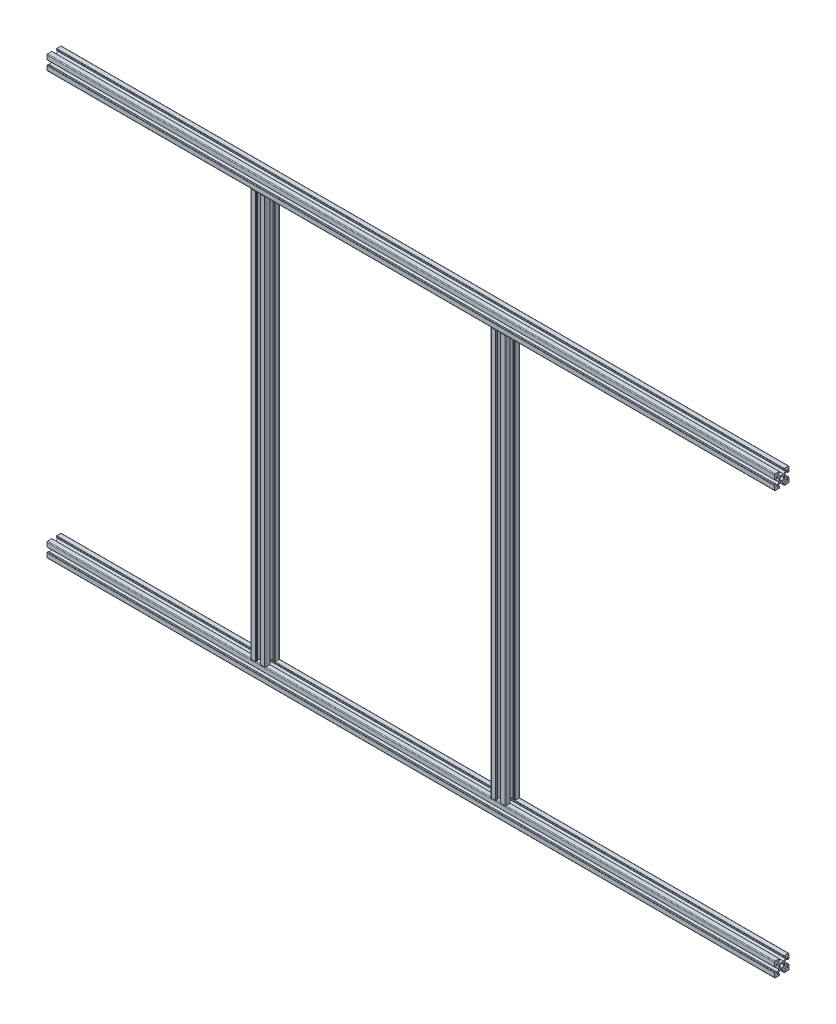
from build123d import *

# Parameters (mm, degrees)
SKETCH1_R                               = 2.5
ALUMINIUM_PROF_ALUMINIUM_PROF_1_DEPTH   = 1000
SKETCH1_ON_SEGMENT_2_R                  = 2.5
ALUMINIUM_PROF_ALUMINIUM_PROF_1_2_DEPTH = 1000
SKETCH11_R                              = 2.5
ALUMINIUM_PROF_ALUMINIUM_PROF_2_DEPTH   = 580
SKETCH11_ON_SEGMENT_2_R                 = 2.5
ALUMINIUM_PROF_ALUMINIUM_PROF_2_2_DEPTH = 580
SKETCH12_R                              = 2.5
CUT_EXTRUDE1_DEPTH                      = 10


with BuildPart() as part:
    # Sketch1 → Aluminium prof ALUMINIUM PROF(1) (new body)
    with BuildSketch(Plane(origin=(-437.898089172, 365.031847134, 0), x_dir=(0, 1, 0), z_dir=(1, 0, 0))):
        with BuildLine():
            Line((-2.5, 4), (2.5, 4))
            Line((2.5, 4), (6.035533906, 7.535533906))
            Line((6.035533906, 7.535533906), (3.535533906, 7.535533906))
            ThreePointArc((3.535533906, 7.535533906), (3.181980515, 7.681980515), (3.035533906, 8.035533906))
            Line((3.035533906, 8.035533906), (3.035533906, 9.535533906))
            ThreePointArc((3.035533906, 9.535533906), (3.181980515, 9.889087297), (3.535533906, 10.035533906))
            Line((3.535533906, 10.035533906), (9.035533906, 10.035533906))
            ThreePointArc((9.035533906, 10.035533906), (9.742640687, 9.742640687), (10.035533906, 9.035533906))
            Line((10.035533906, 9.035533906), (10.035533906, 3.535533906))
            ThreePointArc((10.035533906, 3.535533906), (9.889087297, 3.181980515), (9.535533906, 3.035533906))
            Line((9.535533906, 3.035533906), (8.035533906, 3.035533906))
            ThreePointArc((8.035533906, 3.035533906), (7.681980515, 3.181980515), (7.535533906, 3.535533906))
            Line((7.535533906, 3.535533906), (7.535533906, 6.035533906))
            Line((7.535533906, 6.035533906), (4, 2.5))
            Line((4, 2.5), (4, -2.5))
            Line((4, -2.5), (7.535533906, -6.035533906))
            Line((7.535533906, -6.035533906), (7.535533906, -3.535533906))
            ThreePointArc((7.535533906, -3.535533906), (7.681980515, -3.181980515), (8.035533906, -3.035533906))
            Line((8.035533906, -3.035533906), (9.535533906, -3.035533906))
            ThreePointArc((9.535533906, -3.035533906), (9.889087297, -3.181980515), (10.035533906, -3.535533906))
            Line((10.035533906, -3.535533906), (10.035533906, -9.035533906))
            ThreePointArc((10.035533906, -9.035533906), (9.742640687, -9.742640687), (9.035533906, -10.035533906))
            Line((9.035533906, -10.035533906), (3.535533906, -10.035533906))
            ThreePointArc((3.535533906, -10.035533906), (3.181980515, -9.889087297), (3.035533906, -9.535533906))
            Line((3.035533906, -9.535533906), (3.035533906, -8.035533906))
            ThreePointArc((3.035533906, -8.035533906), (3.181980515, -7.681980515), (3.535533906, -7.535533906))
            Line((3.535533906, -7.535533906), (6.035533906, -7.535533906))
            Line((6.035533906, -7.535533906), (2.5, -4))
            Line((2.5, -4), (-2.5, -4))
            Line((-2.5, -4), (-6.035533906, -7.535533906))
            Line((-6.035533906, -7.535533906), (-3.535533906, -7.535533906))
            ThreePointArc((-3.535533906, -7.535533906), (-3.181980515, -7.681980515), (-3.035533906, -8.035533906))
            Line((-3.035533906, -8.035533906), (-3.035533906, -9.535533906))
            ThreePointArc((-3.035533906, -9.535533906), (-3.181980515, -9.889087297), (-3.535533906, -10.035533906))
            Line((-3.535533906, -10.035533906), (-9.035533906, -10.035533906))
            ThreePointArc((-9.035533906, -10.035533906), (-9.742640687, -9.742640687), (-10.035533906, -9.035533906))
            Line((-10.035533906, -9.035533906), (-10.035533906, -3.535533906))
            ThreePointArc((-10.035533906, -3.535533906), (-9.889087297, -3.181980515), (-9.535533906, -3.035533906))
            Line((-9.535533906, -3.035533906), (-8.035533906, -3.035533906))
            ThreePointArc((-8.035533906, -3.035533906), (-7.681980515, -3.181980515), (-7.535533906, -3.535533906))
            Line((-7.535533906, -3.535533906), (-7.535533906, -6.035533906))
            Line((-7.535533906, -6.035533906), (-4, -2.5))
            Line((-4, -2.5), (-4, 2.5))
            Line((-4, 2.5), (-7.535533906, 6.035533906))
            Line((-7.535533906, 6.035533906), (-7.535533906, 3.535533906))
            ThreePointArc((-7.535533906, 3.535533906), (-7.681980515, 3.181980515), (-8.035533906, 3.035533906))
            Line((-8.035533906, 3.035533906), (-9.535533906, 3.035533906))
            ThreePointArc((-9.535533906, 3.035533906), (-9.889087297, 3.181980515), (-10.035533906, 3.535533906))
            Line((-10.035533906, 3.535533906), (-10.035533906, 9.035533906))
            ThreePointArc((-10.035533906, 9.035533906), (-9.742640687, 9.742640687), (-9.035533906, 10.035533906))
            Line((-9.035533906, 10.035533906), (-3.535533906, 10.035533906))
            ThreePointArc((-3.535533906, 10.035533906), (-3.181980515, 9.889087297), (-3.035533906, 9.535533906))
            Line((-3.035533906, 9.535533906), (-3.035533906, 8.035533906))
            ThreePointArc((-3.035533906, 8.035533906), (-3.181980515, 7.681980515), (-3.535533906, 7.535533906))
            Line((-3.535533906, 7.535533906), (-6.035533906, 7.535533906))
            Line((-6.035533906, 7.535533906), (-2.5, 4))
        make_face()
        Circle(SKETCH1_R, mode=Mode.SUBTRACT)
    extrude(amount=ALUMINIUM_PROF_ALUMINIUM_PROF_1_DEPTH)


with BuildPart() as body_2:
    # Sketch1 on segment 2 (carried to segment 2) → Aluminium prof ALUMINIUM PROF_1 2 (new body)
    with BuildSketch(Plane(origin=(-437.898089172, -214.968152866, 0), x_dir=(0, 1, 0), z_dir=(1, 0, 0))):
        with BuildLine():
            Line((-2.5, 4), (2.5, 4))
            Line((2.5, 4), (6.035533906, 7.535533906))
            Line((6.035533906, 7.535533906), (3.535533906, 7.535533906))
            ThreePointArc((3.535533906, 7.535533906), (3.181980515, 7.681980515), (3.035533906, 8.035533906))
            Line((3.035533906, 8.035533906), (3.035533906, 9.535533906))
            ThreePointArc((3.035533906, 9.535533906), (3.181980515, 9.889087297), (3.535533906, 10.035533906))
            Line((3.535533906, 10.035533906), (9.035533906, 10.035533906))
            ThreePointArc((9.035533906, 10.035533906), (9.742640687, 9.742640687), (10.035533906, 9.035533906))
            Line((10.035533906, 9.035533906), (10.035533906, 3.535533906))
            ThreePointArc((10.035533906, 3.535533906), (9.889087297, 3.181980515), (9.535533906, 3.035533906))
            Line((9.535533906, 3.035533906), (8.035533906, 3.035533906))
            ThreePointArc((8.035533906, 3.035533906), (7.681980515, 3.181980515), (7.535533906, 3.535533906))
            Line((7.535533906, 3.535533906), (7.535533906, 6.035533906))
            Line((7.535533906, 6.035533906), (4, 2.5))
            Line((4, 2.5), (4, -2.5))
            Line((4, -2.5), (7.535533906, -6.035533906))
            Line((7.535533906, -6.035533906), (7.535533906, -3.535533906))
            ThreePointArc((7.535533906, -3.535533906), (7.681980515, -3.181980515), (8.035533906, -3.035533906))
            Line((8.035533906, -3.035533906), (9.535533906, -3.035533906))
            ThreePointArc((9.535533906, -3.035533906), (9.889087297, -3.181980515), (10.035533906, -3.535533906))
            Line((10.035533906, -3.535533906), (10.035533906, -9.035533906))
            ThreePointArc((10.035533906, -9.035533906), (9.742640687, -9.742640687), (9.035533906, -10.035533906))
            Line((9.035533906, -10.035533906), (3.535533906, -10.035533906))
            ThreePointArc((3.535533906, -10.035533906), (3.181980515, -9.889087297), (3.035533906, -9.535533906))
            Line((3.035533906, -9.535533906), (3.035533906, -8.035533906))
            ThreePointArc((3.035533906, -8.035533906), (3.181980515, -7.681980515), (3.535533906, -7.535533906))
            Line((3.535533906, -7.535533906), (6.035533906, -7.535533906))
            Line((6.035533906, -7.535533906), (2.5, -4))
            Line((2.5, -4), (-2.5, -4))
            Line((-2.5, -4), (-6.035533906, -7.535533906))
            Line((-6.035533906, -7.535533906), (-3.535533906, -7.535533906))
            ThreePointArc((-3.535533906, -7.535533906), (-3.181980515, -7.681980515), (-3.035533906, -8.035533906))
            Line((-3.035533906, -8.035533906), (-3.035533906, -9.535533906))
            ThreePointArc((-3.035533906, -9.535533906), (-3.181980515, -9.889087297), (-3.535533906, -10.035533906))
            Line((-3.535533906, -10.035533906), (-9.035533906, -10.035533906))
            ThreePointArc((-9.035533906, -10.035533906), (-9.742640687, -9.742640687), (-10.035533906, -9.035533906))
            Line((-10.035533906, -9.035533906), (-10.035533906, -3.535533906))
            ThreePointArc((-10.035533906, -3.535533906), (-9.889087297, -3.181980515), (-9.535533906, -3.035533906))
            Line((-9.535533906, -3.035533906), (-8.035533906, -3.035533906))
            ThreePointArc((-8.035533906, -3.035533906), (-7.681980515, -3.181980515), (-7.535533906, -3.535533906))
            Line((-7.535533906, -3.535533906), (-7.535533906, -6.035533906))
            Line((-7.535533906, -6.035533906), (-4, -2.5))
            Line((-4, -2.5), (-4, 2.5))
            Line((-4, 2.5), (-7.535533906, 6.035533906))
            Line((-7.535533906, 6.035533906), (-7.535533906, 3.535533906))
            ThreePointArc((-7.535533906, 3.535533906), (-7.681980515, 3.181980515), (-8.035533906, 3.035533906))
            Line((-8.035533906, 3.035533906), (-9.535533906, 3.035533906))
            ThreePointArc((-9.535533906, 3.035533906), (-9.889087297, 3.181980515), (-10.035533906, 3.535533906))
            Line((-10.035533906, 3.535533906), (-10.035533906, 9.035533906))
            ThreePointArc((-10.035533906, 9.035533906), (-9.742640687, 9.742640687), (-9.035533906, 10.035533906))
            Line((-9.035533906, 10.035533906), (-3.535533906, 10.035533906))
            ThreePointArc((-3.535533906, 10.035533906), (-3.181980515, 9.889087297), (-3.035533906, 9.535533906))
            Line((-3.035533906, 9.535533906), (-3.035533906, 8.035533906))
            ThreePointArc((-3.035533906, 8.035533906), (-3.181980515, 7.681980515), (-3.535533906, 7.535533906))
            Line((-3.535533906, 7.535533906), (-6.035533906, 7.535533906))
            Line((-6.035533906, 7.535533906), (-2.5, 4))
        make_face()
        Circle(SKETCH1_ON_SEGMENT_2_R, mode=Mode.SUBTRACT)
    extrude(amount=ALUMINIUM_PROF_ALUMINIUM_PROF_1_2_DEPTH)


with BuildPart() as body_3:
    # Sketch11 → Aluminium prof ALUMINIUM PROF(2) (new body)
    with BuildSketch(Plane(origin=(-147.898089172, 365.031847134, 0), x_dir=(1, 0, 0), z_dir=(0, -1, 0))):
        with BuildLine():
            Line((-2.5, 4), (2.5, 4))
            Line((2.5, 4), (6.035533906, 7.535533906))
            Line((6.035533906, 7.535533906), (3.535533906, 7.535533906))
            ThreePointArc((3.535533906, 7.535533906), (3.181980515, 7.681980515), (3.035533906, 8.035533906))
            Line((3.035533906, 8.035533906), (3.035533906, 9.535533906))
            ThreePointArc((3.035533906, 9.535533906), (3.181980515, 9.889087297), (3.535533906, 10.035533906))
            Line((3.535533906, 10.035533906), (9.035533906, 10.035533906))
            ThreePointArc((9.035533906, 10.035533906), (9.742640687, 9.742640687), (10.035533906, 9.035533906))
            Line((10.035533906, 9.035533906), (10.035533906, 3.535533906))
            ThreePointArc((10.035533906, 3.535533906), (9.889087297, 3.181980515), (9.535533906, 3.035533906))
            Line((9.535533906, 3.035533906), (8.035533906, 3.035533906))
            ThreePointArc((8.035533906, 3.035533906), (7.681980515, 3.181980515), (7.535533906, 3.535533906))
            Line((7.535533906, 3.535533906), (7.535533906, 6.035533906))
            Line((7.535533906, 6.035533906), (4, 2.5))
            Line((4, 2.5), (4, -2.5))
            Line((4, -2.5), (7.535533906, -6.035533906))
            Line((7.535533906, -6.035533906), (7.535533906, -3.535533906))
            ThreePointArc((7.535533906, -3.535533906), (7.681980515, -3.181980515), (8.035533906, -3.035533906))
            Line((8.035533906, -3.035533906), (9.535533906, -3.035533906))
            ThreePointArc((9.535533906, -3.035533906), (9.889087297, -3.181980515), (10.035533906, -3.535533906))
            Line((10.035533906, -3.535533906), (10.035533906, -9.035533906))
            ThreePointArc((10.035533906, -9.035533906), (9.742640687, -9.742640687), (9.035533906, -10.035533906))
            Line((9.035533906, -10.035533906), (3.535533906, -10.035533906))
            ThreePointArc((3.535533906, -10.035533906), (3.181980515, -9.889087297), (3.035533906, -9.535533906))
            Line((3.035533906, -9.535533906), (3.035533906, -8.035533906))
            ThreePointArc((3.035533906, -8.035533906), (3.181980515, -7.681980515), (3.535533906, -7.535533906))
            Line((3.535533906, -7.535533906), (6.035533906, -7.535533906))
            Line((6.035533906, -7.535533906), (2.5, -4))
            Line((2.5, -4), (-2.5, -4))
            Line((-2.5, -4), (-6.035533906, -7.535533906))
            Line((-6.035533906, -7.535533906), (-3.535533906, -7.535533906))
            ThreePointArc((-3.535533906, -7.535533906), (-3.181980515, -7.681980515), (-3.035533906, -8.035533906))
            Line((-3.035533906, -8.035533906), (-3.035533906, -9.535533906))
            ThreePointArc((-3.035533906, -9.535533906), (-3.181980515, -9.889087297), (-3.535533906, -10.035533906))
            Line((-3.535533906, -10.035533906), (-9.035533906, -10.035533906))
            ThreePointArc((-9.035533906, -10.035533906), (-9.742640687, -9.742640687), (-10.035533906, -9.035533906))
            Line((-10.035533906, -9.035533906), (-10.035533906, -3.535533906))
            ThreePointArc((-10.035533906, -3.535533906), (-9.889087297, -3.181980515), (-9.535533906, -3.035533906))
            Line((-9.535533906, -3.035533906), (-8.035533906, -3.035533906))
            ThreePointArc((-8.035533906, -3.035533906), (-7.681980515, -3.181980515), (-7.535533906, -3.535533906))
            Line((-7.535533906, -3.535533906), (-7.535533906, -6.035533906))
            Line((-7.535533906, -6.035533906), (-4, -2.5))
            Line((-4, -2.5), (-4, 2.5))
            Line((-4, 2.5), (-7.535533906, 6.035533906))
            Line((-7.535533906, 6.035533906), (-7.535533906, 3.535533906))
            ThreePointArc((-7.535533906, 3.535533906), (-7.681980515, 3.181980515), (-8.035533906, 3.035533906))
            Line((-8.035533906, 3.035533906), (-9.535533906, 3.035533906))
            ThreePointArc((-9.535533906, 3.035533906), (-9.889087297, 3.181980515), (-10.035533906, 3.535533906))
            Line((-10.035533906, 3.535533906), (-10.035533906, 9.035533906))
            ThreePointArc((-10.035533906, 9.035533906), (-9.742640687, 9.742640687), (-9.035533906, 10.035533906))
            Line((-9.035533906, 10.035533906), (-3.535533906, 10.035533906))
            ThreePointArc((-3.535533906, 10.035533906), (-3.181980515, 9.889087297), (-3.035533906, 9.535533906))
            Line((-3.035533906, 9.535533906), (-3.035533906, 8.035533906))
            ThreePointArc((-3.035533906, 8.035533906), (-3.181980515, 7.681980515), (-3.535533906, 7.535533906))
            Line((-3.535533906, 7.535533906), (-6.035533906, 7.535533906))
            Line((-6.035533906, 7.535533906), (-2.5, 4))
        make_face()
        Circle(SKETCH11_R, mode=Mode.SUBTRACT)
    extrude(amount=ALUMINIUM_PROF_ALUMINIUM_PROF_2_DEPTH)

    # Trim_Extend1 34
    split(bisect_by=Plane.XZ.offset(-354.996313228), keep=Keep.TOP)

    # Trim_Extend1 50
    split(bisect_by=Plane(origin=(62.101910828, -204.93261896, 6.285533906), x_dir=(-1, 0, 0), z_dir=(0, 1, 0)), keep=Keep.TOP)


with BuildPart() as body_4:
    # Sketch11 on segment 2 (carried to segment 2) → Aluminium prof ALUMINIUM PROF_2 2 (new body)
    with BuildSketch(Plane(origin=(182.101910828, 365.031847134, 0), x_dir=(1, 0, 0), z_dir=(0, -1, 0))):
        with BuildLine():
            Line((-2.5, 4), (2.5, 4))
            Line((2.5, 4), (6.035533906, 7.535533906))
            Line((6.035533906, 7.535533906), (3.535533906, 7.535533906))
            ThreePointArc((3.535533906, 7.535533906), (3.181980515, 7.681980515), (3.035533906, 8.035533906))
            Line((3.035533906, 8.035533906), (3.035533906, 9.535533906))
            ThreePointArc((3.035533906, 9.535533906), (3.181980515, 9.889087297), (3.535533906, 10.035533906))
            Line((3.535533906, 10.035533906), (9.035533906, 10.035533906))
            ThreePointArc((9.035533906, 10.035533906), (9.742640687, 9.742640687), (10.035533906, 9.035533906))
            Line((10.035533906, 9.035533906), (10.035533906, 3.535533906))
            ThreePointArc((10.035533906, 3.535533906), (9.889087297, 3.181980515), (9.535533906, 3.035533906))
            Line((9.535533906, 3.035533906), (8.035533906, 3.035533906))
            ThreePointArc((8.035533906, 3.035533906), (7.681980515, 3.181980515), (7.535533906, 3.535533906))
            Line((7.535533906, 3.535533906), (7.535533906, 6.035533906))
            Line((7.535533906, 6.035533906), (4, 2.5))
            Line((4, 2.5), (4, -2.5))
            Line((4, -2.5), (7.535533906, -6.035533906))
            Line((7.535533906, -6.035533906), (7.535533906, -3.535533906))
            ThreePointArc((7.535533906, -3.535533906), (7.681980515, -3.181980515), (8.035533906, -3.035533906))
            Line((8.035533906, -3.035533906), (9.535533906, -3.035533906))
            ThreePointArc((9.535533906, -3.035533906), (9.889087297, -3.181980515), (10.035533906, -3.535533906))
            Line((10.035533906, -3.535533906), (10.035533906, -9.035533906))
            ThreePointArc((10.035533906, -9.035533906), (9.742640687, -9.742640687), (9.035533906, -10.035533906))
            Line((9.035533906, -10.035533906), (3.535533906, -10.035533906))
            ThreePointArc((3.535533906, -10.035533906), (3.181980515, -9.889087297), (3.035533906, -9.535533906))
            Line((3.035533906, -9.535533906), (3.035533906, -8.035533906))
            ThreePointArc((3.035533906, -8.035533906), (3.181980515, -7.681980515), (3.535533906, -7.535533906))
            Line((3.535533906, -7.535533906), (6.035533906, -7.535533906))
            Line((6.035533906, -7.535533906), (2.5, -4))
            Line((2.5, -4), (-2.5, -4))
            Line((-2.5, -4), (-6.035533906, -7.535533906))
            Line((-6.035533906, -7.535533906), (-3.535533906, -7.535533906))
            ThreePointArc((-3.535533906, -7.535533906), (-3.181980515, -7.681980515), (-3.035533906, -8.035533906))
            Line((-3.035533906, -8.035533906), (-3.035533906, -9.535533906))
            ThreePointArc((-3.035533906, -9.535533906), (-3.181980515, -9.889087297), (-3.535533906, -10.035533906))
            Line((-3.535533906, -10.035533906), (-9.035533906, -10.035533906))
            ThreePointArc((-9.035533906, -10.035533906), (-9.742640687, -9.742640687), (-10.035533906, -9.035533906))
            Line((-10.035533906, -9.035533906), (-10.035533906, -3.535533906))
            ThreePointArc((-10.035533906, -3.535533906), (-9.889087297, -3.181980515), (-9.535533906, -3.035533906))
            Line((-9.535533906, -3.035533906), (-8.035533906, -3.035533906))
            ThreePointArc((-8.035533906, -3.035533906), (-7.681980515, -3.181980515), (-7.535533906, -3.535533906))
            Line((-7.535533906, -3.535533906), (-7.535533906, -6.035533906))
            Line((-7.535533906, -6.035533906), (-4, -2.5))
            Line((-4, -2.5), (-4, 2.5))
            Line((-4, 2.5), (-7.535533906, 6.035533906))
            Line((-7.535533906, 6.035533906), (-7.535533906, 3.535533906))
            ThreePointArc((-7.535533906, 3.535533906), (-7.681980515, 3.181980515), (-8.035533906, 3.035533906))
            Line((-8.035533906, 3.035533906), (-9.535533906, 3.035533906))
            ThreePointArc((-9.535533906, 3.035533906), (-9.889087297, 3.181980515), (-10.035533906, 3.535533906))
            Line((-10.035533906, 3.535533906), (-10.035533906, 9.035533906))
            ThreePointArc((-10.035533906, 9.035533906), (-9.742640687, 9.742640687), (-9.035533906, 10.035533906))
            Line((-9.035533906, 10.035533906), (-3.535533906, 10.035533906))
            ThreePointArc((-3.535533906, 10.035533906), (-3.181980515, 9.889087297), (-3.035533906, 9.535533906))
            Line((-3.035533906, 9.535533906), (-3.035533906, 8.035533906))
            ThreePointArc((-3.035533906, 8.035533906), (-3.181980515, 7.681980515), (-3.535533906, 7.535533906))
            Line((-3.535533906, 7.535533906), (-6.035533906, 7.535533906))
            Line((-6.035533906, 7.535533906), (-2.5, 4))
        make_face()
        Circle(SKETCH11_ON_SEGMENT_2_R, mode=Mode.SUBTRACT)
    extrude(amount=ALUMINIUM_PROF_ALUMINIUM_PROF_2_2_DEPTH)

    # Trim_Extend1 34
    split(bisect_by=Plane.XZ.offset(-354.996313228), keep=Keep.TOP)

    # Trim_Extend1 50
    split(bisect_by=Plane(origin=(62.101910828, -204.93261896, 6.285533906), x_dir=(-1, 0, 0), z_dir=(0, 1, 0)), keep=Keep.TOP)


with BuildPart() as cut_extrude1_tool:
    # Sketch12 → Cut-Extrude1 (new body)
    with BuildSketch(Plane.XY.offset(4)):
        with Locations(Location((182.101910828, 365.031847134, 0), (0, 0, 270))):
            Circle(SKETCH12_R)
        with Locations(Location((182.101910828, -214.968152866, 0), (0, 0, 270))):
            Circle(SKETCH12_R)
    extrude(amount=-CUT_EXTRUDE1_DEPTH)


with BuildPart() as part_1:
    add(part.part)

    # Cut-Extrude1: cut by cut_extrude1_tool
    add(cut_extrude1_tool.part, mode=Mode.SUBTRACT)


with BuildPart() as body_2_1:
    add(body_2.part)

    # Cut-Extrude1: cut by cut_extrude1_tool
    add(cut_extrude1_tool.part, mode=Mode.SUBTRACT)


solid = Compound([body_3.part, body_4.part, part_1.part, body_2_1.part])
